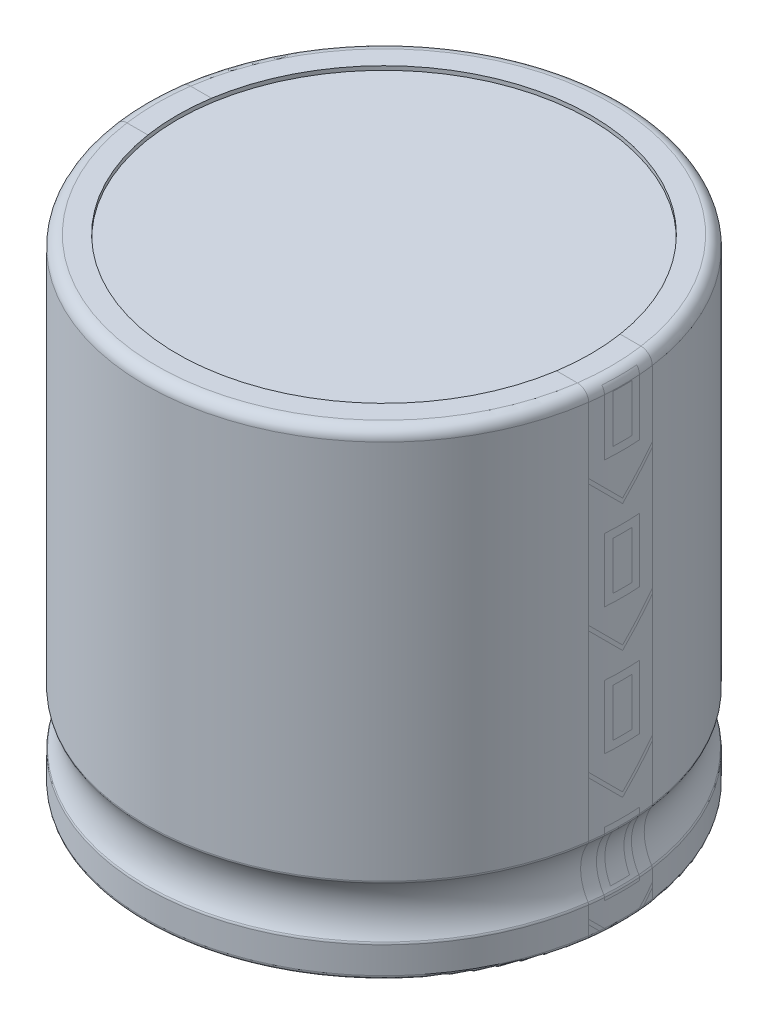
from build123d import *

# Parameters (mm, degrees)
SKETCH4_R           = 0.9
BOSS_EXTRUDE1_DEPTH = 1


with BuildPart() as part:
    # Sketch1 → Revolve1 (revolve)
    with BuildSketch(Plane.XY):
        with BuildLine():
            Line((0, 29.75), (13, 29.75))
            Line((13, 29.75), (13, 30))
            Line((13, 30), (14.3, 30))
            ThreePointArc((14.3, 30), (14.794974747, 29.794974747), (15, 29.3))
            Line((15, 29.3), (15, 5.390363203))
            ThreePointArc((15, 5.390363203), (14.990192231, 5.321025678), (14.961538462, 5.257128525))
            ThreePointArc((14.961538462, 5.257128525), (14.5, 3.658312395), (14.961538462, 2.059496265))
            ThreePointArc((14.961538462, 2.059496265), (14.990192231, 1.995599112), (15, 1.926261588))
            Line((15, 1.926261588), (15, 0.25))
            ThreePointArc((15, 0.25), (14.926776695, 0.073223305), (14.75, 0))
            Line((14.75, 0), (0, 0))
            Line((0, 0), (0, 29.75))
        make_face()
    revolve(axis=Axis((0, 0, 0), (0, 1, 0)))

    # Sketch4 → Boss-Extrude1 (add)
    with BuildSketch(Plane.XZ):
        with Locations((5, 0)):
            Circle(SKETCH4_R)
        with Locations((-5, 0)):
            Circle(SKETCH4_R)
    extrude(amount=BOSS_EXTRUDE1_DEPTH)


solid = part.part
